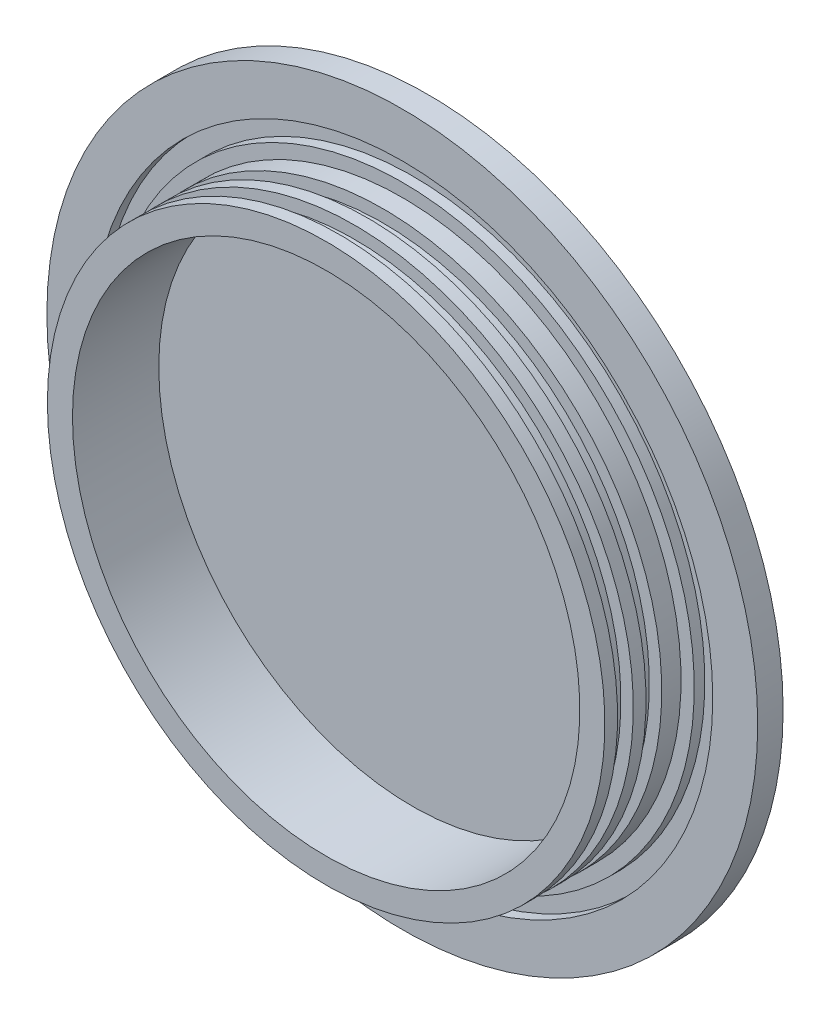
from build123d import *


with BuildPart() as part:
    # Sketch1 → Revolve1 (revolve)
    with BuildSketch(Plane(origin=(0, 0, 0), x_dir=(1, 0, 0), z_dir=(0, 1, 0))):
        Polygon((0, 0), (88.9, 0), (88.9, -6.35), (77.6478, -6.35), (77.6478, -3.7084), (73.025, -3.7084), (73.025, -6.35), (69.723, -6.35), (69.723, -11.176), (66.6242, -11.176), (66.6242, -15.113), (69.723, -15.113), (69.723, -18.288), (66.6242, -18.288), (66.6242, -22.225), (69.723, -22.225), (69.723, -25.4), (63.4492, -25.4), (63.4492, -3.81), (0, -3.81), align=None)
    revolve(axis=Axis((0, 0, 0), (0, 0, 1)))


solid = part.part
